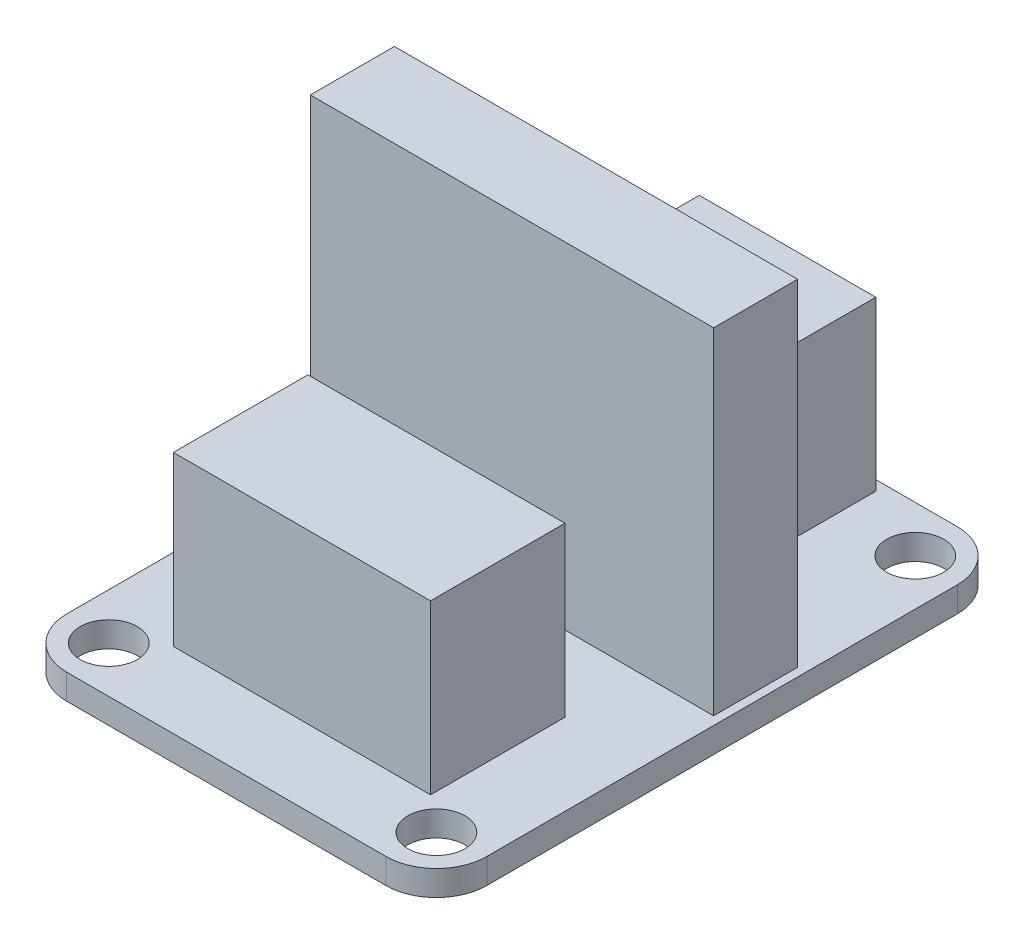
from build123d import *

# Parameters (mm, degrees)
SKIZZE2_W                       = 25
SKIZZE2_H                       = 34
AUFSATZ_LINEAR_AUSTRAGEN1_DEPTH = 1.5
VERRUNDUNG1_R                   = 3
DURCHGANGSLOCH_F_R_M31_D        = 3.4
SKIZZE5_W                       = 24
SKIZZE5_H                       = 5
AUFSATZ_LINEAR_AUSTRAGEN2_DEPTH = 20
SKIZZE6_W                       = 10.5
SKIZZE6_H                       = 8
SKIZZE6_W_2                     = 15.3
AUFSATZ_LINEAR_AUSTRAGEN3_DEPTH = 10


with BuildPart() as part:
    # Skizze2 → Aufsatz-Linear austragen1 (new body)
    with BuildSketch(Plane(origin=(0, 0, 0), x_dir=(1, 0, 0), z_dir=(0, 1, 0))):
        Rectangle(SKIZZE2_W, SKIZZE2_H)
    extrude(amount=AUFSATZ_LINEAR_AUSTRAGEN1_DEPTH)

    # Verrundung1
    verrundung1_edges = [part.edges().sort_by_distance(p)[0] for p in [
        (12.5, 0.75, 17),
        (-12.5, 0.75, 17),
        (-12.5, 0.75, -17),
        (12.5, 0.75, -17),
    ]]
    fillet(verrundung1_edges, radius=VERRUNDUNG1_R)

    # Durchgangsloch für M31 (through all)
    with Locations(Plane(origin=(0, 1.5, 0), x_dir=(1, 0, 0), z_dir=(0, 1, 0))):
        with Locations((-9.75, 14.25), (9.75, 14.25), (9.75, -14.25), (-9.75, -14.25)):
            Hole(DURCHGANGSLOCH_F_R_M31_D / 2)

    # Skizze5 → Aufsatz-Linear austragen2 (add)
    with BuildSketch(Plane(origin=(0, 1.5, 0), x_dir=(1, 0, 0), z_dir=(0, 1, 0))):
        with Locations((0, 2.5)):
            Rectangle(SKIZZE5_W, SKIZZE5_H)
    extrude(amount=AUFSATZ_LINEAR_AUSTRAGEN2_DEPTH)

    # Skizze6 → Aufsatz-Linear austragen3 (add)
    with BuildSketch(Plane(origin=(0, 1.5, 0), x_dir=(1, 0, 0), z_dir=(0, 1, 0))):
        with Locations((0, 12.4)):
            Rectangle(SKIZZE6_W, SKIZZE6_H)
        with Locations((0, -8.5)):
            Rectangle(SKIZZE6_W_2, SKIZZE6_H)
    extrude(amount=AUFSATZ_LINEAR_AUSTRAGEN3_DEPTH)


solid = part.part
